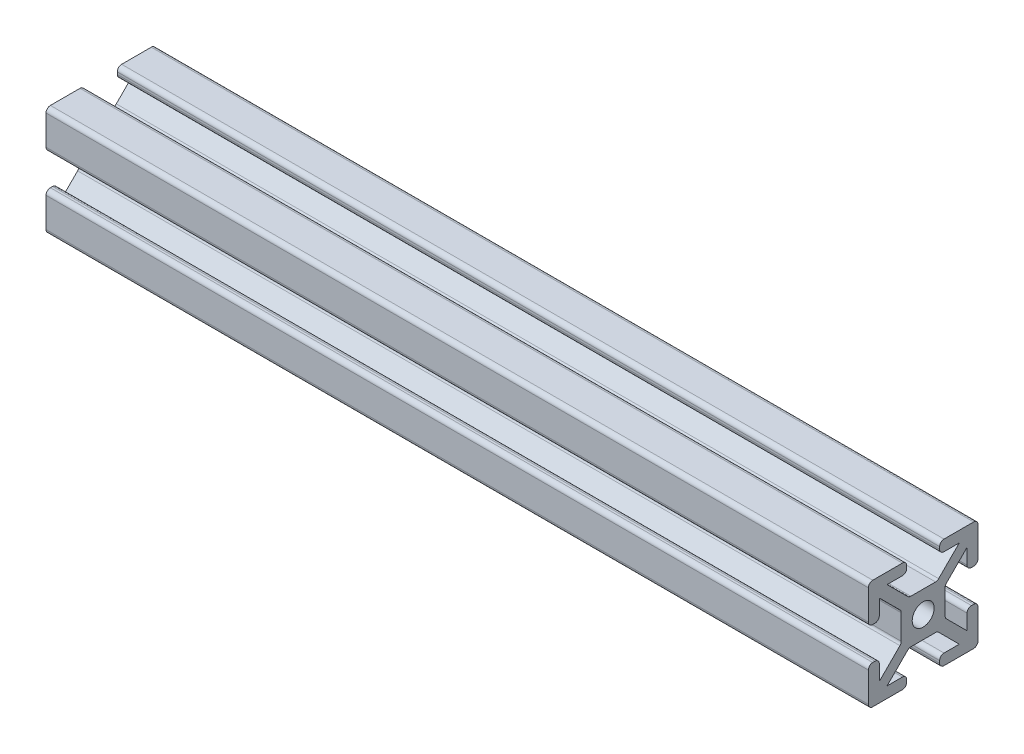
from build123d import *

# Parameters (mm, degrees)
SKETCH11_R       = 2
SIZE_4X4_1_DEPTH = 150


with BuildPart() as part:
    # Sketch11 → Size 4X4 (1) (new body)
    with BuildSketch(Plane(origin=(0, 0, 0), x_dir=(0, 0, -1), z_dir=(1, 0, 0))):
        with BuildLine():
            Line((-3, 9.2), (-3, 8.8))
            ThreePointArc((-3, 8.8), (-3.234314575, 8.234314575), (-3.8, 8))
            Line((-3.8, 8), (-6.585786438, 8))
            Line((-6.585786438, 8), (-2.820101013, 4.234314575))
            ThreePointArc((-2.820101013, 4.234314575), (-2.560562334, 4.060896374), (-2.254415588, 4))
            Line((-2.254415588, 4), (2.254415588, 4))
            ThreePointArc((2.254415588, 4), (2.560562334, 4.060896374), (2.820101013, 4.234314575))
            Line((2.820101013, 4.234314575), (6.585786438, 8))
            Line((6.585786438, 8), (3.8, 8))
            ThreePointArc((3.8, 8), (3.234314575, 8.234314575), (3, 8.8))
            Line((3, 8.8), (3, 9.2))
            ThreePointArc((3, 9.2), (3.234314575, 9.765685425), (3.8, 10))
            Line((3.8, 10), (9.2, 10))
            ThreePointArc((9.2, 10), (9.765685425, 9.765685425), (10, 9.2))
            Line((10, 9.2), (10, 3.8))
            ThreePointArc((10, 3.8), (9.765685425, 3.234314575), (9.2, 3))
            Line((9.2, 3), (8.8, 3))
            ThreePointArc((8.8, 3), (8.234314575, 3.234314575), (8, 3.8))
            Line((8, 3.8), (8, 6.585786438))
            Line((8, 6.585786438), (4.234314575, 2.820101013))
            ThreePointArc((4.234314575, 2.820101013), (4.060896374, 2.560562334), (4, 2.254415588))
            Line((4, 2.254415588), (4, -2.254415588))
            ThreePointArc((4, -2.254415588), (4.060896374, -2.560562334), (4.234314575, -2.820101013))
            Line((4.234314575, -2.820101013), (8, -6.585786438))
            Line((8, -6.585786438), (8, -3.8))
            ThreePointArc((8, -3.8), (8.234314575, -3.234314575), (8.8, -3))
            Line((8.8, -3), (9.2, -3))
            ThreePointArc((9.2, -3), (9.765685425, -3.234314575), (10, -3.8))
            Line((10, -3.8), (10, -9.2))
            ThreePointArc((10, -9.2), (9.765685425, -9.765685425), (9.2, -10))
            Line((9.2, -10), (3.8, -10))
            ThreePointArc((3.8, -10), (3.234314575, -9.765685425), (3, -9.2))
            Line((3, -9.2), (3, -8.8))
            ThreePointArc((3, -8.8), (3.234314575, -8.234314575), (3.8, -8))
            Line((3.8, -8), (6.585786438, -8))
            Line((6.585786438, -8), (2.820101013, -4.234314575))
            ThreePointArc((2.820101013, -4.234314575), (2.560562334, -4.060896374), (2.254415588, -4))
            Line((2.254415588, -4), (-2.254415588, -4))
            ThreePointArc((-2.254415588, -4), (-2.560562334, -4.060896374), (-2.820101013, -4.234314575))
            Line((-2.820101013, -4.234314575), (-6.585786438, -8))
            Line((-6.585786438, -8), (-3.8, -8))
            ThreePointArc((-3.8, -8), (-3.234314575, -8.234314575), (-3, -8.8))
            Line((-3, -8.8), (-3, -9.2))
            ThreePointArc((-3, -9.2), (-3.234314575, -9.765685425), (-3.8, -10))
            Line((-3.8, -10), (-9.2, -10))
            ThreePointArc((-9.2, -10), (-9.765685425, -9.765685425), (-10, -9.2))
            Line((-10, -9.2), (-10, -3.8))
            ThreePointArc((-10, -3.8), (-9.765685425, -3.234314575), (-9.2, -3))
            Line((-9.2, -3), (-8.8, -3))
            ThreePointArc((-8.8, -3), (-8.234314575, -3.234314575), (-8, -3.8))
            Line((-8, -3.8), (-8, -6.585786438))
            Line((-8, -6.585786438), (-4.234314575, -2.820101013))
            ThreePointArc((-4.234314575, -2.820101013), (-4.060896374, -2.560562334), (-4, -2.254415588))
            Line((-4, -2.254415588), (-4, 2.254415588))
            ThreePointArc((-4, 2.254415588), (-4.060896374, 2.560562334), (-4.234314575, 2.820101013))
            Line((-4.234314575, 2.820101013), (-8, 6.585786438))
            Line((-8, 6.585786438), (-8, 3.8))
            ThreePointArc((-8, 3.8), (-8.234314575, 3.234314575), (-8.8, 3))
            Line((-8.8, 3), (-9.2, 3))
            ThreePointArc((-9.2, 3), (-9.765685425, 3.234314575), (-10, 3.8))
            Line((-10, 3.8), (-10, 9.2))
            ThreePointArc((-10, 9.2), (-9.765685425, 9.765685425), (-9.2, 10))
            Line((-9.2, 10), (-3.8, 10))
            ThreePointArc((-3.8, 10), (-3.234314575, 9.765685425), (-3, 9.2))
        make_face()
        Circle(SKETCH11_R, mode=Mode.SUBTRACT)
    extrude(amount=SIZE_4X4_1_DEPTH)


solid = part.part
